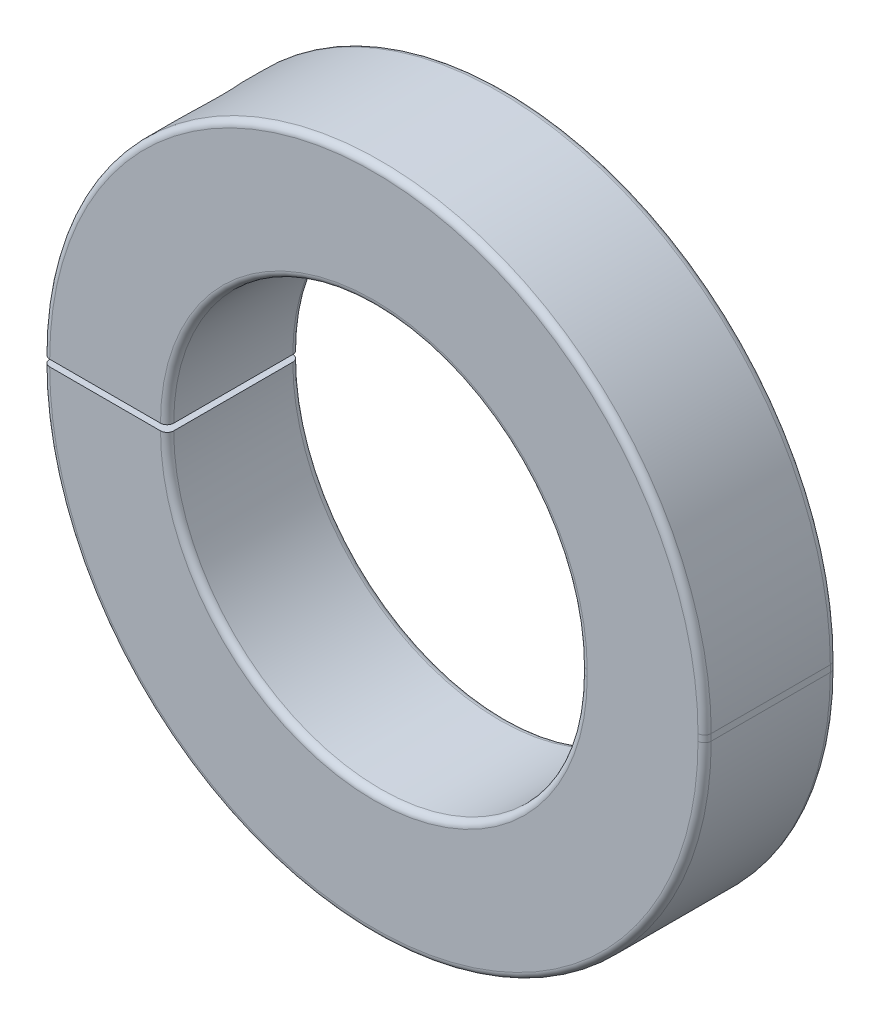
from build123d import *

# Parameters (mm, degrees)
EXTRUDE1_DEPTH     = 6.35
CUT_EXTRUDE2_DEPTH = 3.175
FILLET1_R          = 0.635
CHAMFER2_SIZE      = 0.254


with BuildPart() as part:
    # Sketch1 → Extrude1 (new, symmetric)
    with BuildSketch(Plane.XY):
        with BuildLine():
            Line((-31.75, 0.3175), (-19.84375, 0.3175))
            ThreePointArc((-19.84375, 0.3175), (0, 20.16125), (19.84375, 0.3175))
            Line((19.84375, 0.3175), (19.84375, -0.3175))
            ThreePointArc((19.84375, -0.3175), (0, -20.16125), (-19.84375, -0.3175))
            Line((-19.84375, -0.3175), (-31.75, -0.3175))
            ThreePointArc((-31.75, -0.3175), (0, -32.0675), (31.75, -0.3175))
            Line((31.75, -0.3175), (31.75, 0.3175))
            ThreePointArc((31.75, 0.3175), (0, 32.0675), (-31.75, 0.3175))
        make_face()
    extrude(amount=EXTRUDE1_DEPTH, both=True)

    # Sketch4 → Cut-Revolve1 (revolve, cut)
    with BuildSketch(Plane.XY, mode=Mode.PRIVATE) as cut_revolve1_sk:
        Polygon((-25.796875, 32.0675), (-21.034375, 32.0675), (-21.034375, 3.4925), (-22.621875, 3.4925), (-22.621875, -32.0675), (-25.796875, -32.0675), align=None)
    revolve(cut_revolve1_sk.sketch.rotate(Axis((-25.796875, -32.0675, 0), (0, 1, 0)), 90), axis=Axis((-25.796875, -32.0675, 0), (0, 1, 0)), mode=Mode.SUBTRACT)

    # Fillet1
    fillet1_edges = [part.edges().sort_by_distance(p)[0] for p in [
        (0, 20.16125, 6.35),
        (19.84375, 0, 6.35),
        (0, -20.16125, 6.35),
        (0, -32.0675, 6.35),
        (31.75, 0, 6.35),
        (0, 32.0675, 6.35),
        (31.75, 0, -6.35),
        (0, -32.0675, -6.35),
        (0, -20.16125, -6.35),
        (19.84375, 0, -6.35),
        (0, 20.16125, -6.35),
        (0, 32.0675, -6.35),
    ]]
    fillet(fillet1_edges, radius=FILLET1_R)


with BuildPart() as body_2:
    # Sketch6 → Revolve1 (revolve)
    with BuildSketch(Plane.XY):
        Polygon((-25.796875, 9.8425), (-21.034375, 9.8425), (-21.034375, 3.4925), (-22.621875, 3.4925), (-22.621875, -9.2075), (-25.796875, -9.2075), align=None)
    revolve(axis=Axis((-25.796875, -9.2075, 0), (0, 1, 0)))

    # Sketch7 → Cut-Extrude2 (cut)
    with BuildSketch(Plane(origin=(0, 9.8425, 0), x_dir=(-1, 0, 0), z_dir=(0, 1, 0))):
        Polygon((25.796875, -2.932939367), (28.336875, -1.466469684), (28.336875, 1.466469684), (25.796875, 2.932939367), (23.256875, 1.466469684), (23.256875, -1.466469684), align=None)
    extrude(amount=-CUT_EXTRUDE2_DEPTH, mode=Mode.SUBTRACT)

    # Chamfer2
    chamfer2_edges = [body_2.edges().sort_by_distance(p)[0] for p in [
        (-30.559375, 9.8425, 0),
    ]]
    chamfer(chamfer2_edges, length=CHAMFER2_SIZE)


solid = Compound([part.part, body_2.part])
